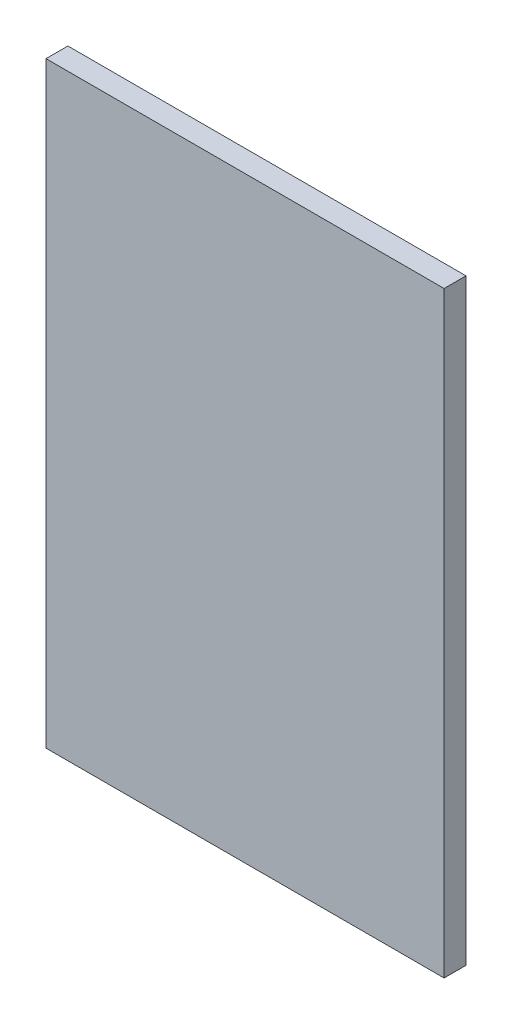
from build123d import *

# Parameters (mm, degrees)
SKETCH_1_W      = 20
SKETCH_1_H      = 30
EXTRUDE_1_DEPTH = 1.1


with BuildPart() as part:
    # 草图1 → 凸台-拉伸1 (new body)
    with BuildSketch(Plane.XY):
        Rectangle(SKETCH_1_W, SKETCH_1_H)
    extrude(amount=EXTRUDE_1_DEPTH)


solid = part.part
